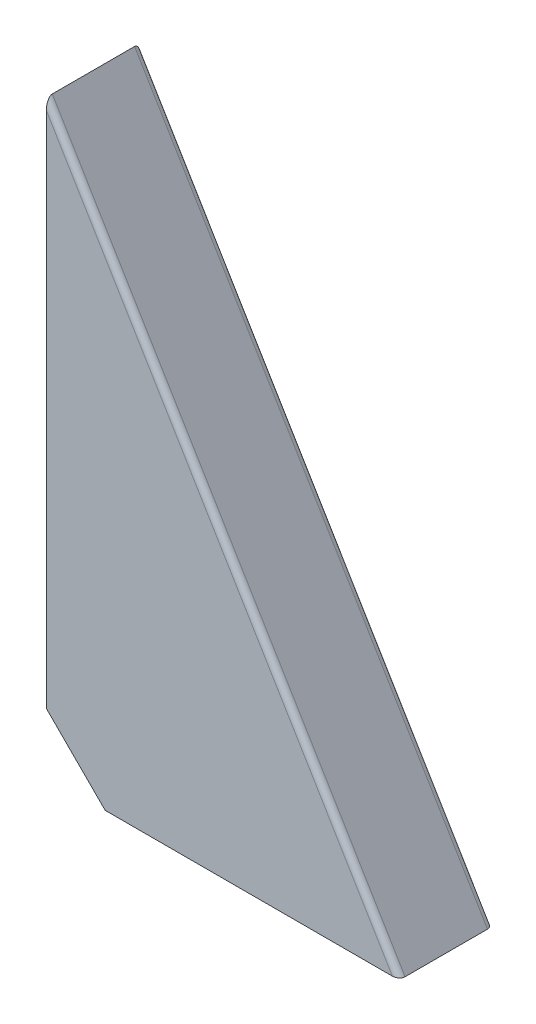
from build123d import *

# Parameters (mm, degrees)
BOSS_EXTRUDE1_DEPTH = 8
CUT_EXTRUDE1_DEPTH  = 17
FILLET1_R           = 1


with BuildPart() as part:
    # Sketch1 → Boss-Extrude1 (new body, symmetric)
    with BuildSketch(Plane.XY):
        Polygon((0, 0), (60, 0), (0, 100), align=None)
    extrude(amount=BOSS_EXTRUDE1_DEPTH, both=True)

    # Sketch2 → Cut-Extrude1 (cut, through all)
    with BuildSketch(Plane.XY.offset(8)):
        Polygon((0, 0), (0, 10), (10, 0), align=None)
    extrude(amount=-CUT_EXTRUDE1_DEPTH, mode=Mode.SUBTRACT)

    # Fillet1
    fillet1_edges = [part.edges().sort_by_distance(p)[0] for p in [
        (30, 50, 8),
        (30, 50, -8),
    ]]
    fillet(fillet1_edges, radius=FILLET1_R)


solid = part.part
